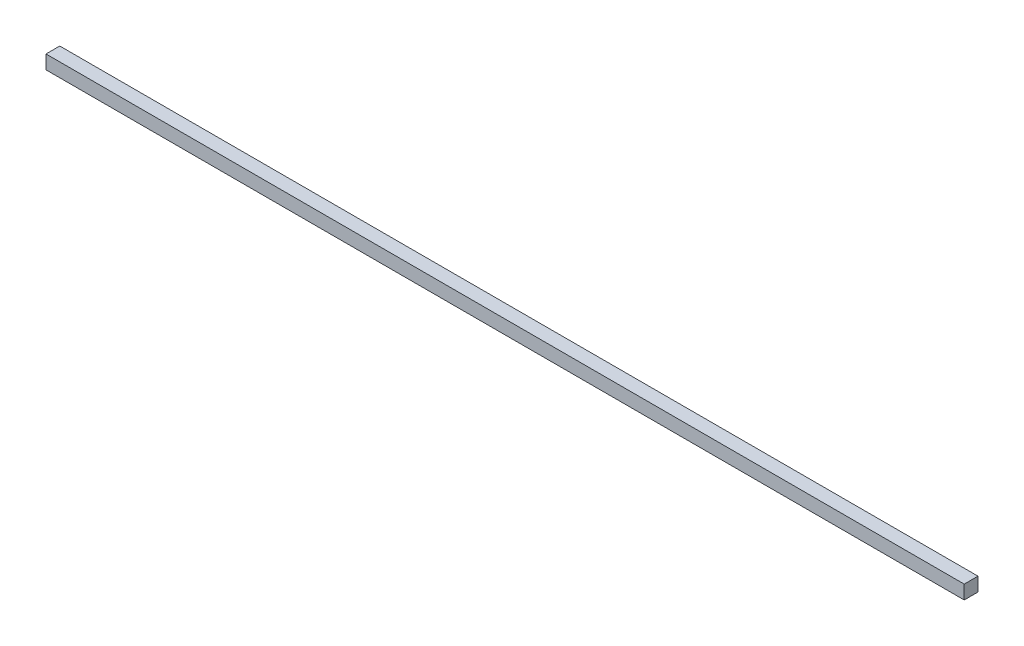
from build123d import *

# Parameters (mm, degrees)
ESQUISSE1_W        = 200
ESQUISSE1_H        = 3
BOSS_EXTRU_1_DEPTH = 3


with BuildPart() as part:
    # Esquisse1 → Boss.-Extru.1 (new body)
    with BuildSketch(Plane.XY):
        with Locations((-13.813370474, -34.990250696)):
            Rectangle(ESQUISSE1_W, ESQUISSE1_H)
    extrude(amount=BOSS_EXTRU_1_DEPTH)


solid = part.part
